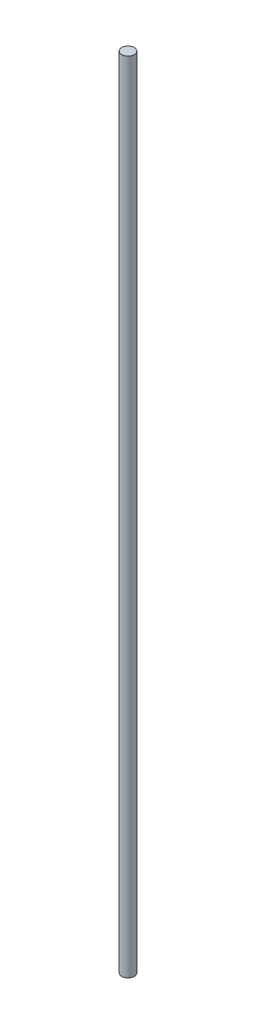
from build123d import *

# Parameters (mm, degrees)
SKETCH1_R           = 1.5875
BOSS_EXTRUDE1_DEPTH = 203.2


with BuildPart() as part:
    # Sketch1 → Boss-Extrude1 (new body)
    with BuildSketch(Plane(origin=(0, 0, 0), x_dir=(1, 0, 0), z_dir=(0, 1, 0))):
        Circle(SKETCH1_R)
    extrude(amount=BOSS_EXTRUDE1_DEPTH)


solid = part.part
